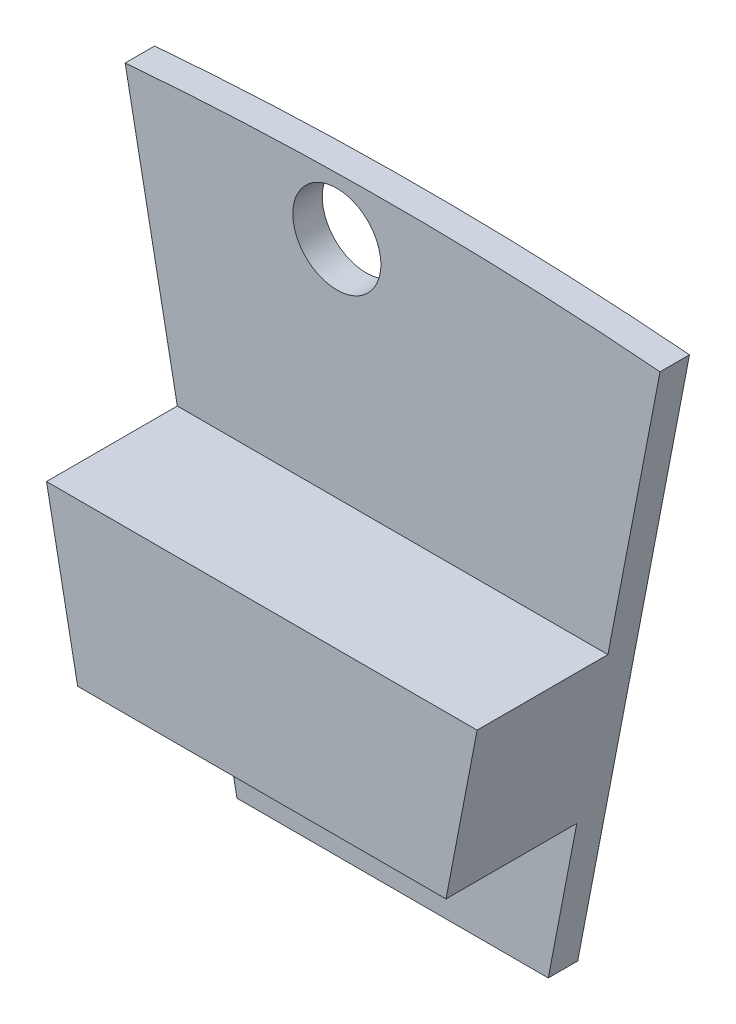
from build123d import *

# Parameters (mm, degrees)
EXTRUDE1_DEPTH     = 4.9
EXTRUDE2_DEPTH     = 0.9
SKETCH3_R          = 1.3462
CUT_EXTRUDE2_DEPTH = 5.9


with BuildPart() as part:
    # Sketch1 → Extrude1 (new body)
    with BuildSketch(Plane.XY):
        Polygon((-6.583958388, 90.87662316), (6.583958388, 90.87662316), (5.632133126, 85.929746212), (-5.632133126, 85.929746212), align=None)
    extrude(amount=EXTRUDE1_DEPTH)

    # Sketch2 → Extrude2 (add)
    with BuildSketch(Plane(origin=(0, 0, 0), x_dir=(-1, 0, 0), z_dir=(0, 0, -1))):
        with BuildLine():
            Line((8.178395959, 99.163319022), (6.538639227, 90.641088001))
            ThreePointArc((6.538639227, 90.641088001), (0, 90.87662316), (-6.538639227, 90.641088001))
            Line((-6.538639227, 90.641088001), (-8.178395959, 99.163319022))
            ThreePointArc((-8.178395959, 99.163319022), (0, 99.5), (8.178395959, 99.163319022))
        make_face()
        with BuildLine():
            Line((5.632133126, 85.929746212), (4.760567707, 81.4))
            Line((4.760567707, 81.4), (-4.760567707, 81.4))
            Line((-4.760567707, 81.4), (-5.632133126, 85.929746212))
            ThreePointArc((-5.632133126, 85.929746212), (0, 86.11412316), (5.632133126, 85.929746212))
        make_face()
    extrude(amount=-EXTRUDE2_DEPTH)

    # Sketch3 → Cut-Extrude2 (cut, through all)
    with BuildSketch(Plane.XY):
        with Locations(Location((-1.705972729, 97.735112202, 0), (0, 0, 180))):  # turned: the seam where the file's is
            Circle(SKETCH3_R)
        with BuildLine():
            Line((-1.069188916, 83.994208969), (-1.051733851, 82.994208969))
            ThreePointArc((-1.051733851, 82.994208969), (-1.441621981, 82.590467992), (-1.845362959, 82.980356122))
            Line((-1.845362959, 82.980356122), (-1.862818024, 83.980356122))
            ThreePointArc((-1.862818024, 83.980356122), (-1.472929894, 84.3840971), (-1.069188916, 83.994208969))
        make_face()
    extrude(amount=CUT_EXTRUDE2_DEPTH, mode=Mode.SUBTRACT)


solid = part.part
